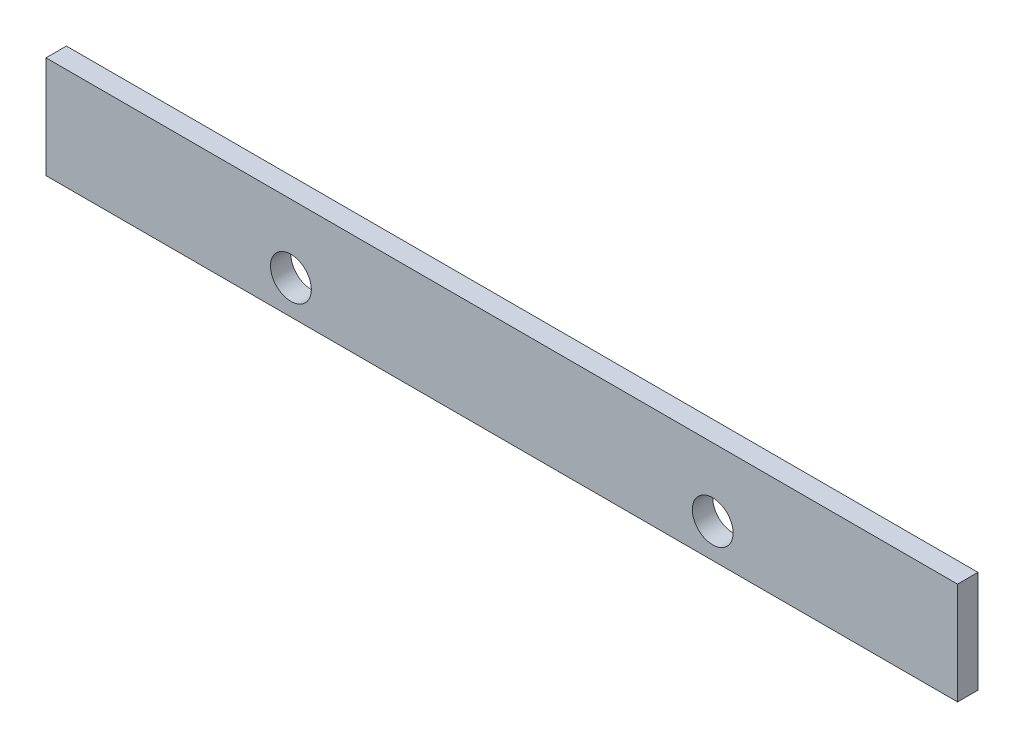
from build123d import *

# Parameters (mm, degrees)
SKETCH1_W           = 134
SKETCH1_H           = 15
BOSS_EXTRUDE1_DEPTH = 3
SKETCH4_R           = 3
CUT_EXTRUDE1_DEPTH  = 3
SKETCH2_R           = 3
CUT_EXTRUDE2_DEPTH  = 3


with BuildPart() as part:
    # Sketch1 → Boss-Extrude1 (new body)
    with BuildSketch(Plane.XY):
        Rectangle(SKETCH1_W, SKETCH1_H)
    extrude(amount=BOSS_EXTRUDE1_DEPTH)

    # Sketch4 → Cut-Extrude1 (cut)
    with BuildSketch(Plane(origin=(0, 0, 0), x_dir=(-1, 0, 0), z_dir=(0, 0, -1))):
        with Locations((-31, -2.5)):
            Circle(SKETCH4_R)
    extrude(amount=-CUT_EXTRUDE1_DEPTH, mode=Mode.SUBTRACT)

    # Sketch2 → Cut-Extrude2 (cut)
    with BuildSketch(Plane(origin=(0, 0, 0), x_dir=(-1, 0, 0), z_dir=(0, 0, -1))):
        with Locations((31, -2.5)):
            Circle(SKETCH2_R)
    extrude(amount=-CUT_EXTRUDE2_DEPTH, mode=Mode.SUBTRACT)


solid = part.part
